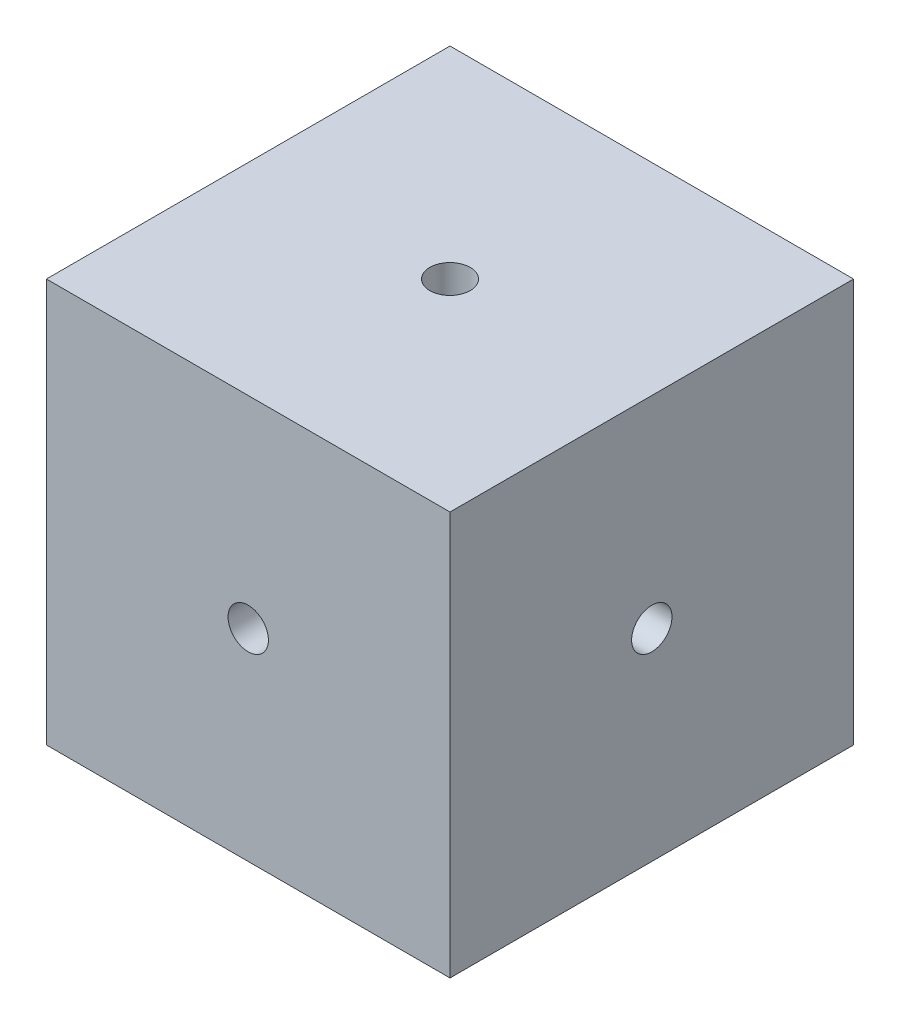
from build123d import *

# Parameters (mm, degrees)
SKETCH1_W           = 70
SKETCH1_H           = 70
BOSS_EXTRUDE1_DEPTH = 35
SKETCH2_R           = 3.5
CUT_EXTRUDE1_DEPTH  = 71
SKETCH3_R           = 3.5
CUT_EXTRUDE2_DEPTH  = 71
SKETCH4_R           = 3.5
CUT_EXTRUDE3_DEPTH  = 71
CUT_EXTRUDE4_DEPTH  = 1


with BuildPart() as part:
    # Sketch1 → Boss-Extrude1 (new body, symmetric)
    with BuildSketch(Plane(origin=(0, 0, 0), x_dir=(1, 0, 0), z_dir=(0, 1, 0))):
        Rectangle(SKETCH1_W, SKETCH1_H)
    extrude(amount=BOSS_EXTRUDE1_DEPTH, both=True)

    # Sketch2 → Cut-Extrude1 (cut, through all)
    with BuildSketch(Plane(origin=(0, 35, 0), x_dir=(1, 0, 0), z_dir=(0, 1, 0))):
        Circle(SKETCH2_R)
    extrude(amount=-CUT_EXTRUDE1_DEPTH, mode=Mode.SUBTRACT)

    # Sketch3 → Cut-Extrude2 (cut, through all)
    with BuildSketch(Plane.XY.offset(35)):
        Circle(SKETCH3_R)
    extrude(amount=-CUT_EXTRUDE2_DEPTH, mode=Mode.SUBTRACT)

    # Sketch4 → Cut-Extrude3 (cut, through all)
    with BuildSketch(Plane(origin=(35, 0, 0), x_dir=(0, 0, -1), z_dir=(1, 0, 0))):
        Circle(SKETCH4_R)
    extrude(amount=-CUT_EXTRUDE3_DEPTH, mode=Mode.SUBTRACT)

    # Sketch5 → Cut-Extrude4 (cut)
    with BuildSketch(Plane.XZ.offset(35)):
        Polygon((7.303847577, -10.5), (7.303847577, -9), (12.5, -12), (7.303847577, -15), (7.303847577, -13.5), (-12.5, -13.5), (-12.5, -10.5), align=None)
    extrude(amount=-CUT_EXTRUDE4_DEPTH, mode=Mode.SUBTRACT)


solid = part.part
